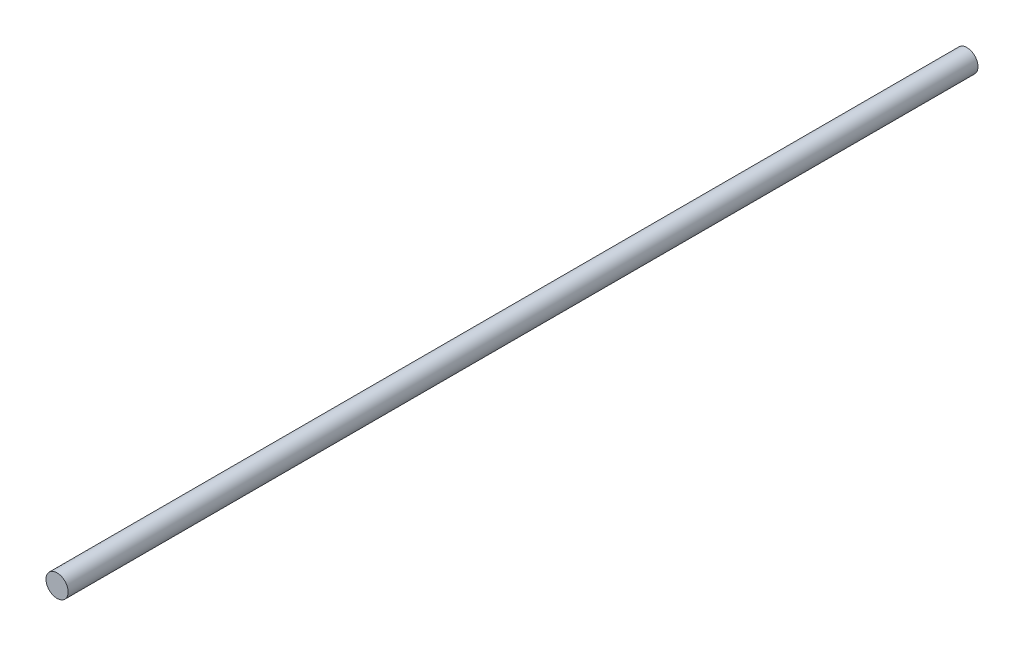
from build123d import *

# Parameters (mm, degrees)
SKETCH1_R           = 5
BOSS_EXTRUDE1_DEPTH = 205


with BuildPart() as part:
    # Sketch1 → Boss-Extrude1 (new body, symmetric)
    with BuildSketch(Plane.XY):
        Circle(SKETCH1_R)
    extrude(amount=BOSS_EXTRUDE1_DEPTH, both=True)


solid = part.part
